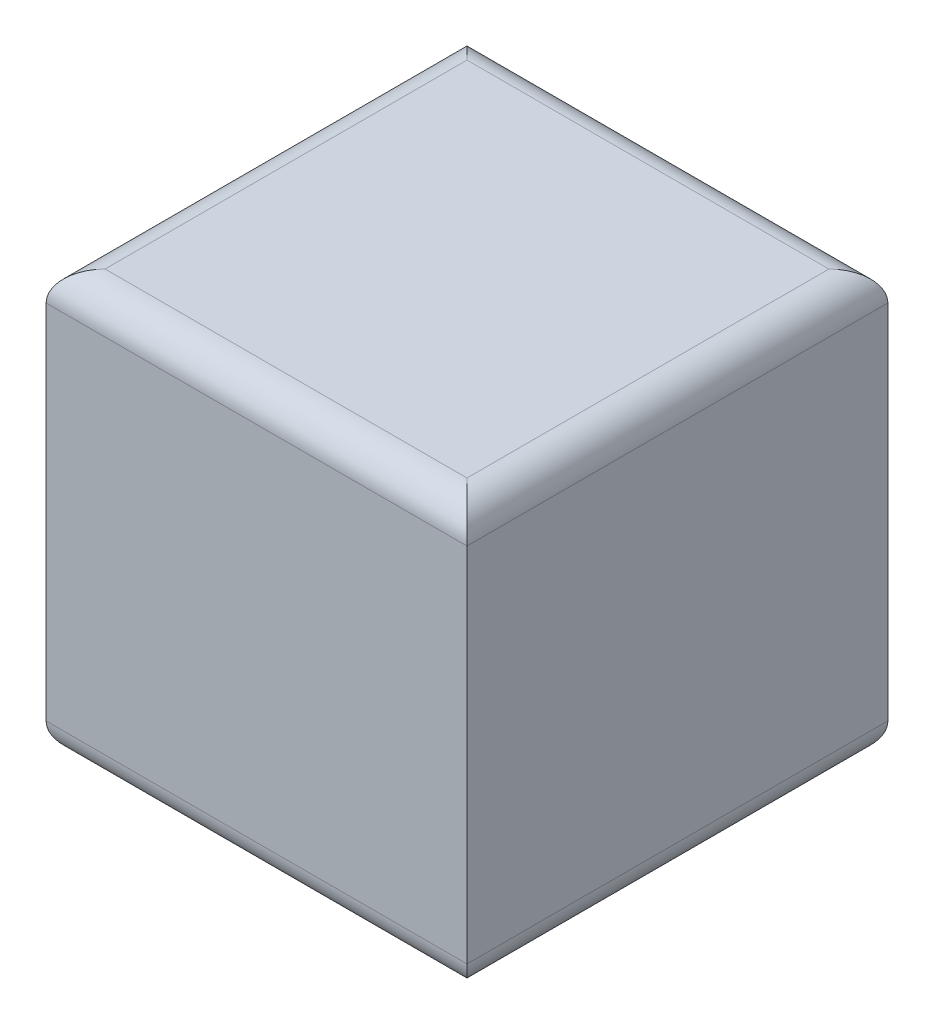
from build123d import *

# Parameters (mm, degrees)
SKETCH1_W           = 1000
SKETCH1_H           = 1000
BOSS_EXTRUDE2_DEPTH = 1000
FILLET2_R           = 70


with BuildPart() as part:
    # Sketch1 → Boss-Extrude2 (new body)
    with BuildSketch(Plane(origin=(0, 0, 0), x_dir=(1, 0, 0), z_dir=(0, 1, 0))):
        with Locations((500, 500)):
            Rectangle(SKETCH1_W, SKETCH1_H)
    extrude(amount=BOSS_EXTRUDE2_DEPTH)

    # Fillet2
    fillet2_edges = [part.edges().sort_by_distance(p)[0] for p in [
        (1000, 1000, -500),
        (500, 1000, -1000),
        (0, 1000, -500),
        (500, 0, -1000),
        (1000, 0, -500),
        (500, 0, 0),
        (0, 0, -500),
        (500, 1000, 0),
    ]]
    fillet(fillet2_edges, radius=FILLET2_R)


solid = part.part
